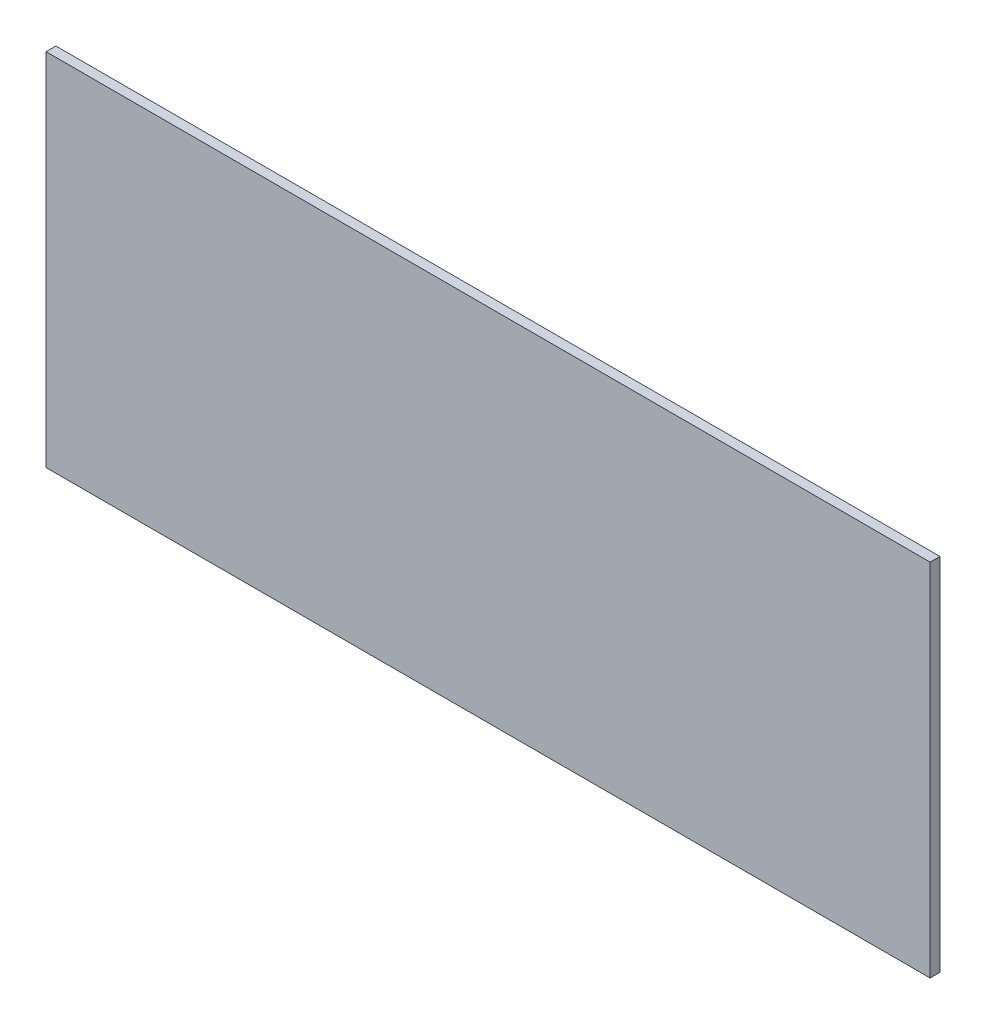
from build123d import *

# Parameters (mm, degrees)
SKETCH_1_W      = 540
SKETCH_1_H      = 220
EXTRUDE_1_DEPTH = 6


with BuildPart() as part:
    # Эскиз1 → Бобышка-Вытянуть1 (new body)
    with BuildSketch(Plane.XY):
        Rectangle(SKETCH_1_W, SKETCH_1_H)
    extrude(amount=EXTRUDE_1_DEPTH)


solid = part.part
